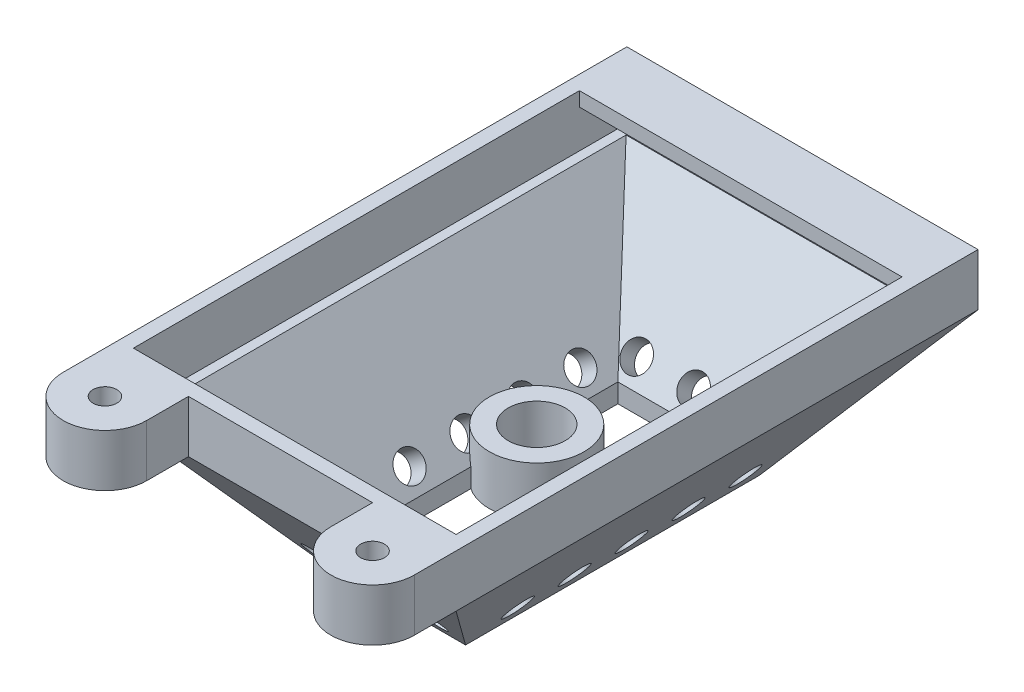
from build123d import *

# Parameters (mm, degrees)
SKETCH1_W            = 7.49
SKETCH1_H            = 15.49
SKETCH2_W            = 18.5
SKETCH2_H            = 27.5
SKETCH3_R            = 1.5
CUT_EXTRUDE1_DEPTH   = 19.108423622
SHELL1_T             = -1
SKETCH19_R           = 2.5
CUT_EXTRUDE5_DEPTH   = 4.7
SKETCH4_R            = 0.75
CUT_EXTRUDE2_DEPTH   = 20.461883068
SKETCH5_R            = 0.75
CUT_EXTRUDE3_DEPTH   = 23.46603426
CUT_EXTRUDE4_DEPTH   = 18.728931323
SKETCH7_W            = 18.5
SKETCH7_H            = 27.5
SKETCH7_W_2          = 17
SKETCH7_H_2          = 26
SKETCH7_W_3          = 15.6
SKETCH7_H_3          = 24.6
BOSS_EXTRUDE2_DEPTH  = 2.75
SKETCH16_R           = 0.625
BOSS_EXTRUDE9_DEPTH  = 2.75
SKETCH18_W           = 17
SKETCH18_H           = 2.5
BOSS_EXTRUDE10_DEPTH = 0.75


with BuildPart() as part:
    # Sketch1 → Loft5 section 0
    with BuildSketch(Plane(origin=(0, 0, 0), x_dir=(1, 0, 0), z_dir=(0, 1, 0))):
        Rectangle(SKETCH1_W, SKETCH1_H)
    # Sketch2 → Loft5 section 1
    with BuildSketch(Plane(origin=(0, 7.3, 0), x_dir=(1, 0, 0), z_dir=(0, 1, 0))):
        Rectangle(SKETCH2_W, SKETCH2_H)
    loft()

    # Sketch3 → Cut-Extrude1 (cut, through all)
    with BuildSketch(Plane.XZ):
        with Locations(Location((-1.85, -1.6, 0), (0, 0, 270))):
            Circle(SKETCH3_R)
    extrude(amount=-CUT_EXTRUDE1_DEPTH, mode=Mode.SUBTRACT)

    # Shell1
    shell1_openings = [part.faces().sort_by_distance(p)[0] for p in [
        (0.026066103, 7.3, 0.022543657),
    ]]
    offset(amount=SHELL1_T, openings=shell1_openings)

    # Sketch19 → Cut-Extrude5 (cut)
    with BuildSketch(Plane(origin=(0, 7.3, 0), x_dir=(1, 0, 0), z_dir=(0, 1, 0))):
        with Locations(Location((-1.85, 1.6, 0), (0, 0, 123.96288881))):
            Circle(SKETCH19_R)
    extrude(amount=-CUT_EXTRUDE5_DEPTH, mode=Mode.SUBTRACT)

    # Sketch4 → Cut-Extrude2 (cut, through all)
    with BuildSketch(Plane(origin=(1.588933313, -1.198229848, 0), x_dir=(0.6020978928410136, 0.7984222738854493, 0), z_dir=(-0.7984222738854493, 0.6020978928410136, 0))):
        with Locations(Location((3.923217088, 0, 0), (0, 0, 180))):
            Circle(SKETCH4_R)
        with Locations(Location((3.923217088, 3, 0), (0, 0, 180))):
            Circle(SKETCH4_R)
        with Locations(Location((3.923217088, 6, 0), (0, 0, 180))):
            Circle(SKETCH4_R)
        with Locations(Location((3.923217088, -3, 0), (0, 0, 180))):
            Circle(SKETCH4_R)
        with Locations(Location((3.923217088, -6, 0), (0, 0, 180))):
            Circle(SKETCH4_R)
    cut_extrude2 = extrude(amount=-CUT_EXTRUDE2_DEPTH, mode=Mode.SUBTRACT)

    # Mirror1: Cut-Extrude2 across plane
    add(cut_extrude2.mirror(Plane(origin=(0, 0, 0), x_dir=(0, 0, 1), z_dir=(1, 0, 0))), mode=Mode.SUBTRACT)

    # Sketch5 → Cut-Extrude3 (cut, through all)
    with BuildSketch(Plane(origin=(0, -3.164535708, -3.846979295), x_dir=(1, 0, 0), z_dir=(0, 0.6352807161040013, 0.7722813035069459))):
        with Locations(Location((-3, 6.562511368, 0), (0, 0, 270))):
            Circle(SKETCH5_R)
        with Locations(Location((0, 6.562511368, 0), (0, 0, 270))):
            Circle(SKETCH5_R)
        with Locations(Location((3, 6.562511368, 0), (0, 0, 270))):
            Circle(SKETCH5_R)
    cut_extrude3 = extrude(amount=-CUT_EXTRUDE3_DEPTH, mode=Mode.SUBTRACT)

    # Mirror2: Cut-Extrude3 across plane
    add(cut_extrude3.mirror(Plane.XY), mode=Mode.SUBTRACT)

    # Sketch6 → Cut-Extrude4 (cut, through all)
    with BuildSketch(Plane(origin=(0, 1, 0), x_dir=(1, 0, 0), z_dir=(0, 1, 0))):
        with BuildLine():
            ThreePointArc((-3.246639521, 3.673498987), (0.65, 1.6), (-3.246639521, -0.473498987))
            Line((-3.246639521, -0.473498987), (-3.246639521, -7.272737779))
            Line((-3.246639521, -7.272737779), (3.246639521, -7.272737779))
            Line((3.246639521, -7.272737779), (3.246639521, 7.272737779))
            Line((3.246639521, 7.272737779), (-3.246639521, 7.272737779))
            Line((-3.246639521, 7.272737779), (-3.246639521, 3.673498987))
        make_face()
    extrude(amount=-CUT_EXTRUDE4_DEPTH, mode=Mode.SUBTRACT)

    # Sketch7 → Boss-Extrude2 (add)
    with BuildSketch(Plane(origin=(0, 7.3, 0), x_dir=(1, 0, 0), z_dir=(0, 1, 0))):
        Rectangle(SKETCH7_W, SKETCH7_H)
        Rectangle(SKETCH7_W_2, SKETCH7_H_2, mode=Mode.SUBTRACT)
        Rectangle(SKETCH7_W_3, SKETCH7_H_3)
    extrude(amount=BOSS_EXTRUDE2_DEPTH)


with BuildPart() as boss_extrude2_kept_piece:
    # of the separate pieces the step leaves, the one the design keeps (boss_extrude2_pieces_kept)
    add(part.part.solids().sort_by_distance((-3.745, 0, 7.745))[0])

    # Sketch16 → Boss-Extrude9 (add)
    with BuildSketch(Plane(origin=(0, 10.05, 0), x_dir=(1, 0, 0), z_dir=(0, 1, 0))):
        with BuildLine():
            Line((-9.25, -13.75), (-9.25, -15.95))
            ThreePointArc((-9.25, -15.95), (-7.05, -18.15), (-4.85, -15.95))
            Line((-4.85, -15.95), (-4.85, -13.75))
            Line((-4.85, -13.75), (-9.25, -13.75))
        make_face()
        with Locations(Location((-7.05, -15.95, 0), (0, 0, 270))):
            Circle(SKETCH16_R, mode=Mode.SUBTRACT)
    boss_extrude9 = extrude(amount=-BOSS_EXTRUDE9_DEPTH)

    # Mirror7: Boss-Extrude9 across plane
    add(boss_extrude9.mirror(Plane(origin=(0, 0, 0), x_dir=(0, 0, 1), z_dir=(1, 0, 0))))

    # Sketch18 → Boss-Extrude10 (add)
    with BuildSketch(Plane(origin=(0, 10.05, 0), x_dir=(1, 0, 0), z_dir=(0, 1, 0))):
        with Locations((0, 11.75)):
            Rectangle(SKETCH18_W, SKETCH18_H)
    extrude(amount=-BOSS_EXTRUDE10_DEPTH)


solid = boss_extrude2_kept_piece.part
